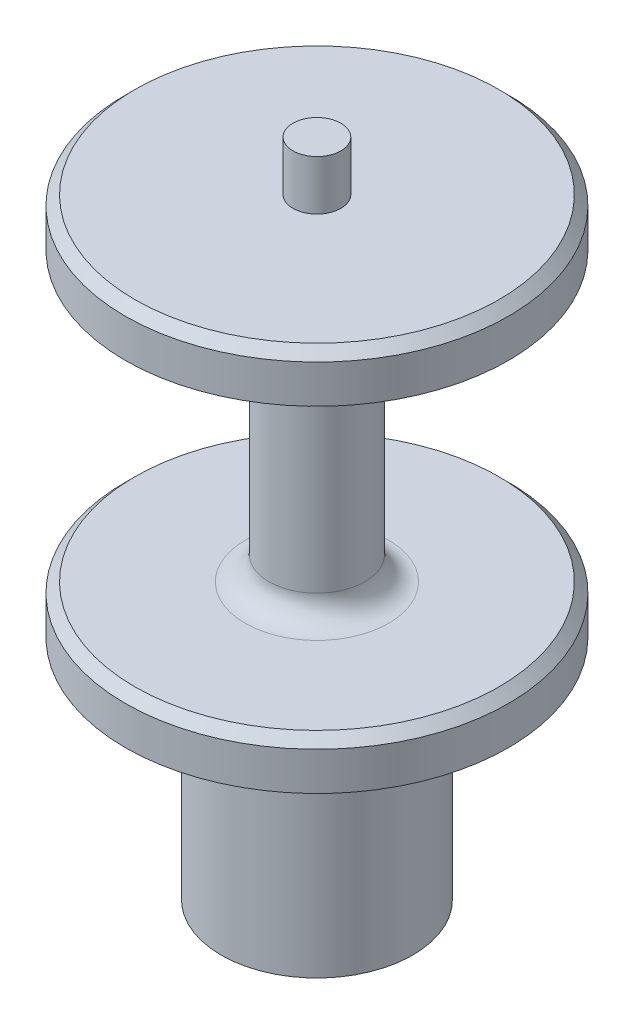
from build123d import *

# Parameters (mm, degrees)
SKETCH1_R           = 12.7
BOSS_EXTRUDE1_DEPTH = 30.1625
SKETCH4_R           = 25.4
BOSS_EXTRUDE2_DEPTH = 50.8
CUT_EXTRUDE1_DEPTH  = 11.176
SKETCH3_R           = 6
CUT_EXTRUDE2_DEPTH  = 8
SKETCH5_R           = 3.175
BOSS_EXTRUDE3_DEPTH = 6.604
CUT_EXTRUDE3_START  = -6.35
SKETCH9_R           = 25.4
SKETCH9_R_2         = 6.35
CUT_EXTRUDE3_DEPTH  = 38.1
FILLET1_R           = 3.175
CHAMFER1_SIZE       = 1.27


with BuildPart() as part:
    # Sketch1 → Boss-Extrude1 (new body)
    with BuildSketch(Plane(origin=(0, 0, 0), x_dir=(1, 0, 0), z_dir=(0, 1, 0))):
        Circle(SKETCH1_R)
    extrude(amount=BOSS_EXTRUDE1_DEPTH)

    # Sketch4 → Boss-Extrude2 (add)
    with BuildSketch(Plane(origin=(0, 30.1625, 0), x_dir=(1, 0, 0), z_dir=(0, 1, 0))):
        Circle(SKETCH4_R)
    extrude(amount=BOSS_EXTRUDE2_DEPTH)

    # Sketch2 → Cut-Extrude1 (cut)
    with BuildSketch(Plane.XZ):
        with BuildLine():
            Line((-7, 2.899494937), (-8.776962921, 1.122532015))
            ThreePointArc((-8.776962921, 1.122532015), (-9.241930906, 0), (-8.776962921, -1.122532015))
            Line((-8.776962921, -1.122532015), (-7, -2.899494937))
            Line((-7, -2.899494937), (-7, 2.899494937))
        make_face()
        Polygon((-2.899494937, 7), (-7, 2.899494937), (-7, -2.899494937), (-2.899494937, -7), (2.899494937, -7), (7, -2.899494937), (7, 2.899494937), (2.899494937, 7), align=None)
        with BuildLine():
            Line((-7, 5.4125), (-7, 2.899494937))
            Line((-7, 2.899494937), (-2.899494937, 7))
            Line((-2.899494937, 7), (-5.4125, 7))
            ThreePointArc((-5.4125, 7), (-6.535032015, 6.535032015), (-7, 5.4125))
        make_face()
        with BuildLine():
            Line((-1.122532015, 8.776962921), (-2.899494937, 7))
            Line((-2.899494937, 7), (2.899494937, 7))
            Line((2.899494937, 7), (1.122532015, 8.776962921))
            ThreePointArc((1.122532015, 8.776962921), (0, 9.241930906), (-1.122532015, 8.776962921))
        make_face()
        with BuildLine():
            Line((5.4125, 7), (2.899494937, 7))
            Line((2.899494937, 7), (7, 2.899494937))
            Line((7, 2.899494937), (7, 5.4125))
            ThreePointArc((7, 5.4125), (6.535032015, 6.535032015), (5.4125, 7))
        make_face()
        with BuildLine():
            Line((8.776962921, 1.122532015), (7, 2.899494937))
            Line((7, 2.899494937), (7, -2.899494937))
            Line((7, -2.899494937), (8.776962921, -1.122532015))
            ThreePointArc((8.776962921, -1.122532015), (9.241930906, 0), (8.776962921, 1.122532015))
        make_face()
        with BuildLine():
            Line((7, -2.899494937), (2.899494937, -7))
            Line((2.899494937, -7), (5.4125, -7))
            ThreePointArc((5.4125, -7), (6.535032015, -6.535032015), (7, -5.4125))
            Line((7, -5.4125), (7, -2.899494937))
        make_face()
        with BuildLine():
            Line((2.899494937, -7), (-2.899494937, -7))
            Line((-2.899494937, -7), (-1.122532015, -8.776962921))
            ThreePointArc((-1.122532015, -8.776962921), (0, -9.241930906), (1.122532015, -8.776962921))
            Line((1.122532015, -8.776962921), (2.899494937, -7))
        make_face()
        with BuildLine():
            Line((-2.899494937, -7), (-7, -2.899494937))
            Line((-7, -2.899494937), (-7, -5.4125))
            ThreePointArc((-7, -5.4125), (-6.535032015, -6.535032015), (-5.4125, -7))
            Line((-5.4125, -7), (-2.899494937, -7))
        make_face()
    extrude(amount=-CUT_EXTRUDE1_DEPTH, mode=Mode.SUBTRACT)

    # Sketch3 → Cut-Extrude2 (cut)
    with BuildSketch(Plane.XZ.offset(-11.176)):
        Circle(SKETCH3_R)
    extrude(amount=-CUT_EXTRUDE2_DEPTH, mode=Mode.SUBTRACT)

    # Sketch5 → Boss-Extrude3 (add)
    with BuildSketch(Plane(origin=(0, 80.9625, 0), x_dir=(1, 0, 0), z_dir=(0, 1, 0))):
        Circle(SKETCH5_R)
    extrude(amount=BOSS_EXTRUDE3_DEPTH)

    # Sketch9 → Cut-Extrude3 (cut)
    with BuildSketch(Plane(origin=(0, 80.9625, 0), x_dir=(1, 0, 0), z_dir=(0, 1, 0)).offset(CUT_EXTRUDE3_START)):
        Circle(SKETCH9_R)
        Circle(SKETCH9_R_2, mode=Mode.SUBTRACT)
    extrude(amount=-CUT_EXTRUDE3_DEPTH, mode=Mode.SUBTRACT)

    # Fillet1
    fillet1_edges = [part.edges().sort_by_distance(p)[0] for p in [
        (-6.35, 36.5125, 0),
        (-6.35, 74.6125, 0),
    ]]
    fillet(fillet1_edges, radius=FILLET1_R)

    # Chamfer1
    chamfer1_edges = [part.edges().sort_by_distance(p)[0] for p in [
        (-25.4, 80.9625, 0),
        (-25.4, 36.5125, 0),
    ]]
    chamfer(chamfer1_edges, length=CHAMFER1_SIZE)


solid = part.part
